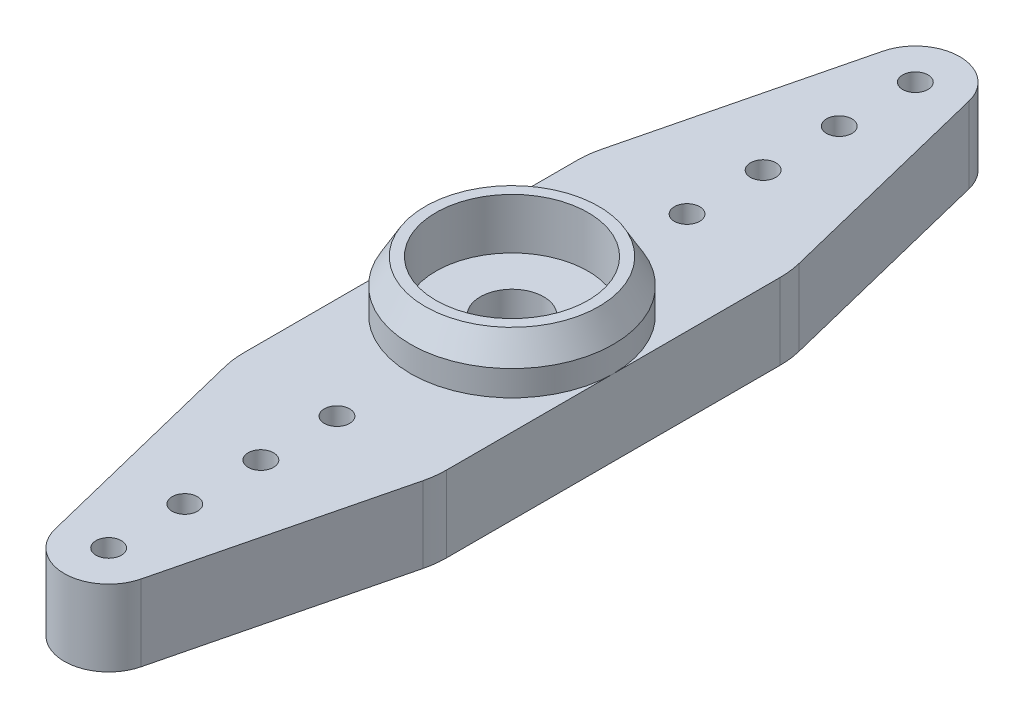
from build123d import *

# Parameters (mm, degrees)
CROQUIS1_R              = 0.5
SALIENTE_EXTRUIR1_DEPTH = 3
MATRIZC1_COUNT          = 2
CROQUIS2_R              = 4
CROQUIS2_R_2            = 3
SALIENTE_EXTRUIR2_DEPTH = 2
CHAFL_N1_SIZE           = 1
CHAFL_N1_SIZE2          = 0.577350269


with BuildPart() as part:
    # Croquis1 → Saliente-Extruir1 (new body)
    with BuildSketch(Plane(origin=(0, 0, 0), x_dir=(1, 0, 0), z_dir=(0, 1, 0))):
        with BuildLine():
            Line((-4, 0), (-4, 6.574293681))
            ThreePointArc((-4, 6.574293681), (-3.974394349, 6.996885575), (-3.897952052, 7.413294188))
            Line((-3.897952052, 7.413294188), (-1.698976026, 16.319147094))
            ThreePointArc((-1.698976026, 16.319147094), (0, 17.649646841), (1.698976026, 16.319147094))
            Line((1.698976026, 16.319147094), (3.897952052, 7.413294188))
            ThreePointArc((3.897952052, 7.413294188), (3.974394349, 6.996885575), (4, 6.574293681))
            Line((4, 6.574293681), (4, 0))
            Line((4, 0), (1.25, 0))
            ThreePointArc((1.25, 0), (0, 1.25), (-1.25, 0))
            Line((-1.25, 0), (-4, 0))
        make_face()
        with Locations((0, 15.899646841)):
            Circle(CROQUIS1_R, mode=Mode.SUBTRACT)
        with Locations((0, 12.899646841)):
            Circle(CROQUIS1_R, mode=Mode.SUBTRACT)
        with Locations((0, 9.899646841)):
            Circle(CROQUIS1_R, mode=Mode.SUBTRACT)
        with Locations((0, 6.899646841)):
            Circle(CROQUIS1_R, mode=Mode.SUBTRACT)
    saliente_extruir1 = extrude(amount=SALIENTE_EXTRUIR1_DEPTH)

    # MatrizC1: Saliente-Extruir1 ×2 about axis
    matrizc1_axis = Axis((0, 0, 0), (0, 1, 0))
    for i in range(1, MATRIZC1_COUNT):
        add(saliente_extruir1.rotate(matrizc1_axis, i * 360 / MATRIZC1_COUNT))

    # Croquis2 → Saliente-Extruir2 (add)
    with BuildSketch(Plane(origin=(0, 3, 0), x_dir=(1, 0, 0), z_dir=(0, 1, 0))):
        Circle(CROQUIS2_R)
        Circle(CROQUIS2_R_2, mode=Mode.SUBTRACT)
    extrude(amount=SALIENTE_EXTRUIR2_DEPTH)

    # Chaflán1
    chafl_n1_edges = [part.edges().sort_by_distance(p)[0] for p in [
        (-4, 5, 0),
    ]]
    chafl_n1_side = [part.faces().sort_by_distance(p)[0] for p in [
        (-4, 4, 0),
    ]]
    chamfer(chafl_n1_edges, length=CHAFL_N1_SIZE, length2=CHAFL_N1_SIZE2, reference=chafl_n1_side[0])


solid = part.part
